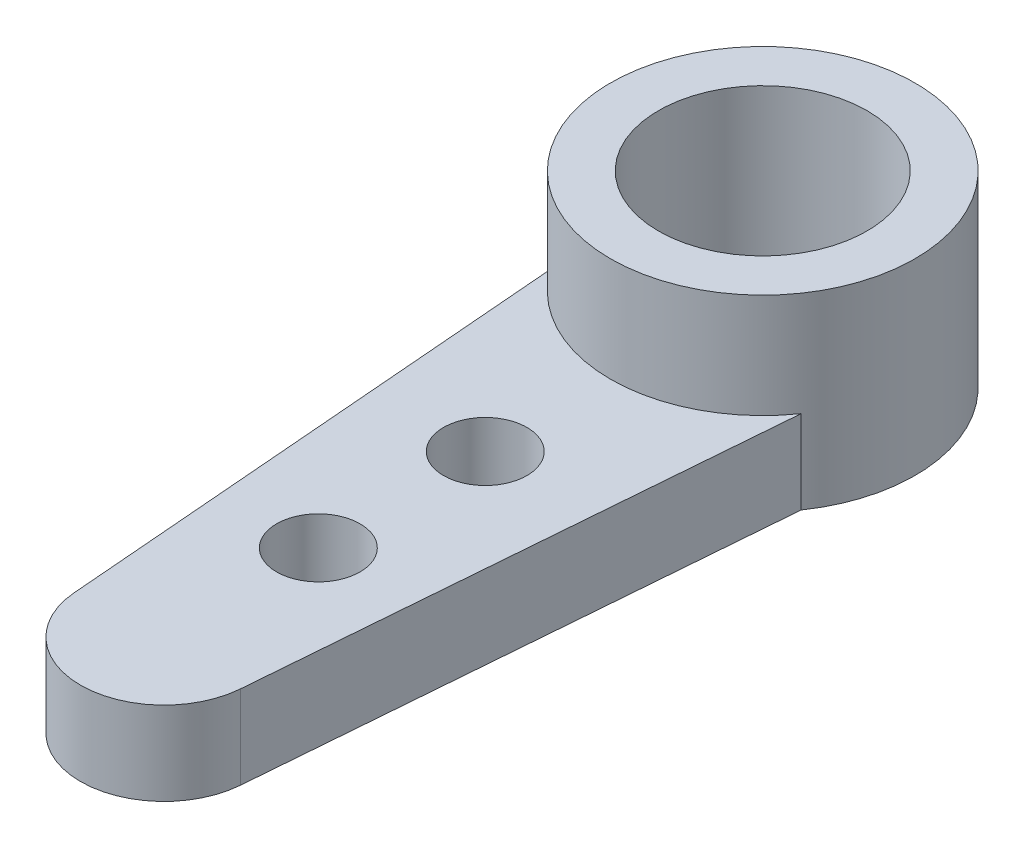
from build123d import *

# Parameters (mm, degrees)
SKETCH1_R           = 1
SKETCH1_R_2         = 2.5
BOSS_EXTRUDE1_DEPTH = 2
SKETCH2_R           = 3.65
SKETCH2_R_2         = 2.5
BOSS_EXTRUDE2_DEPTH = 2.5


with BuildPart() as part:
    # Sketch1 → Boss-Extrude1 (new body)
    with BuildSketch(Plane(origin=(0, 0, 0), x_dir=(1, 0, 0), z_dir=(0, 1, 0))):
        with BuildLine():
            Line((3, -2.079062289), (1.993477511, -14.51139211))
            ThreePointArc((1.993477511, -14.51139211), (0, -16.35), (-1.993477511, -14.51139211))
            Line((-1.993477511, -14.51139211), (-3, -2.079062289))
            ThreePointArc((-3, -2.079062289), (0, 3.65), (3, -2.079062289))
        make_face()
        with Locations((0, -6.65)):
            Circle(SKETCH1_R, mode=Mode.SUBTRACT)
        with Locations((0, -10.65)):
            Circle(SKETCH1_R, mode=Mode.SUBTRACT)
        Circle(SKETCH1_R_2, mode=Mode.SUBTRACT)
    extrude(amount=BOSS_EXTRUDE1_DEPTH)

    # Sketch2 → Boss-Extrude2 (add)
    with BuildSketch(Plane(origin=(0, 2, 0), x_dir=(1, 0, 0), z_dir=(0, 1, 0))):
        Circle(SKETCH2_R)
        Circle(SKETCH2_R_2, mode=Mode.SUBTRACT)
    extrude(amount=BOSS_EXTRUDE2_DEPTH)


solid = part.part
